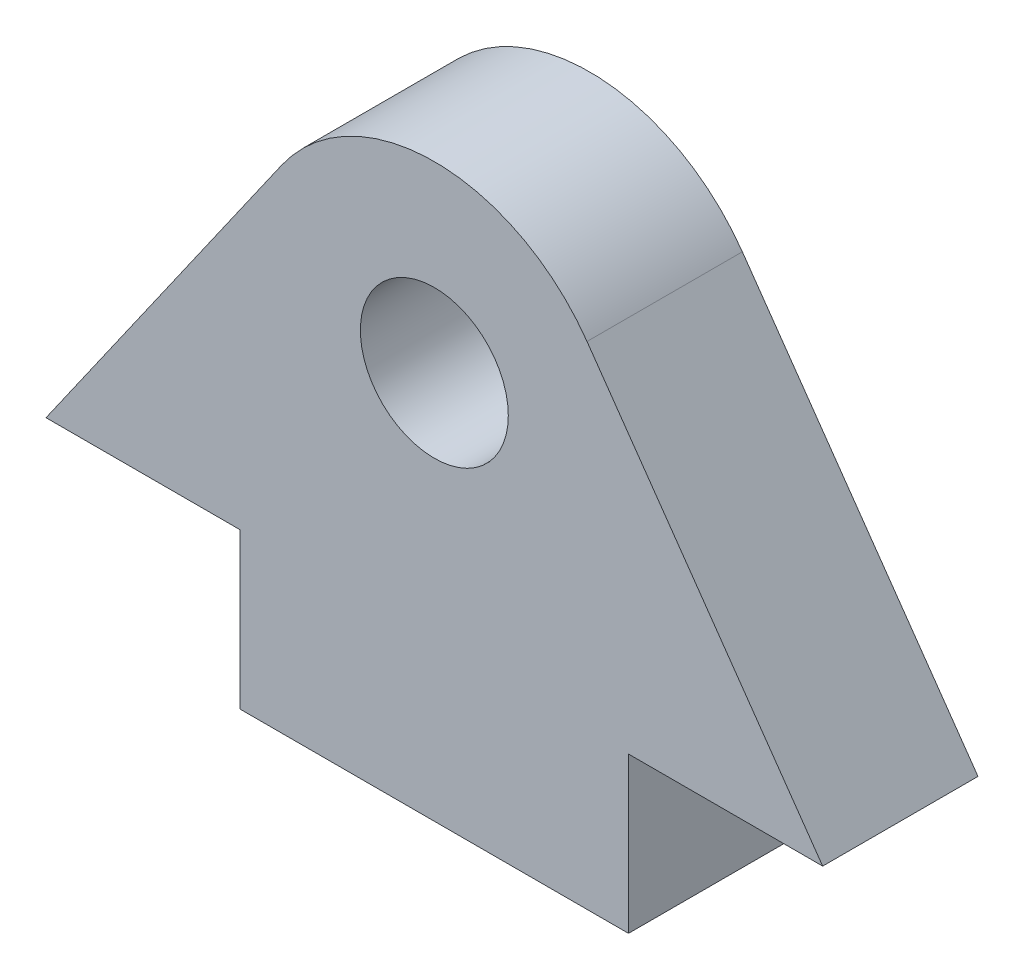
from build123d import *

# Parameters (mm, degrees)
SKETCH1_R           = 4.7625
SKETCH1_W           = 25
SKETCH1_H           = 10
BOSS_EXTRUDE1_DEPTH = 10
FILLET1_R           = 12


with BuildPart() as part:
    # Sketch1 → Boss-Extrude1 (new body)
    with BuildSketch(Plane.XY):
        Polygon((50, 0), (25, 35.703700169), (0, 0), align=None)
        with Locations((25, 15)):
            Circle(SKETCH1_R, mode=Mode.SUBTRACT)
        with Locations((25, -5)):
            Rectangle(SKETCH1_W, SKETCH1_H)
    extrude(amount=BOSS_EXTRUDE1_DEPTH)

    # Fillet1
    fillet1_edges = [part.edges().sort_by_distance(p)[0] for p in [
        (25, 35.703700169, 5),
    ]]
    fillet(fillet1_edges, radius=FILLET1_R)


solid = part.part
